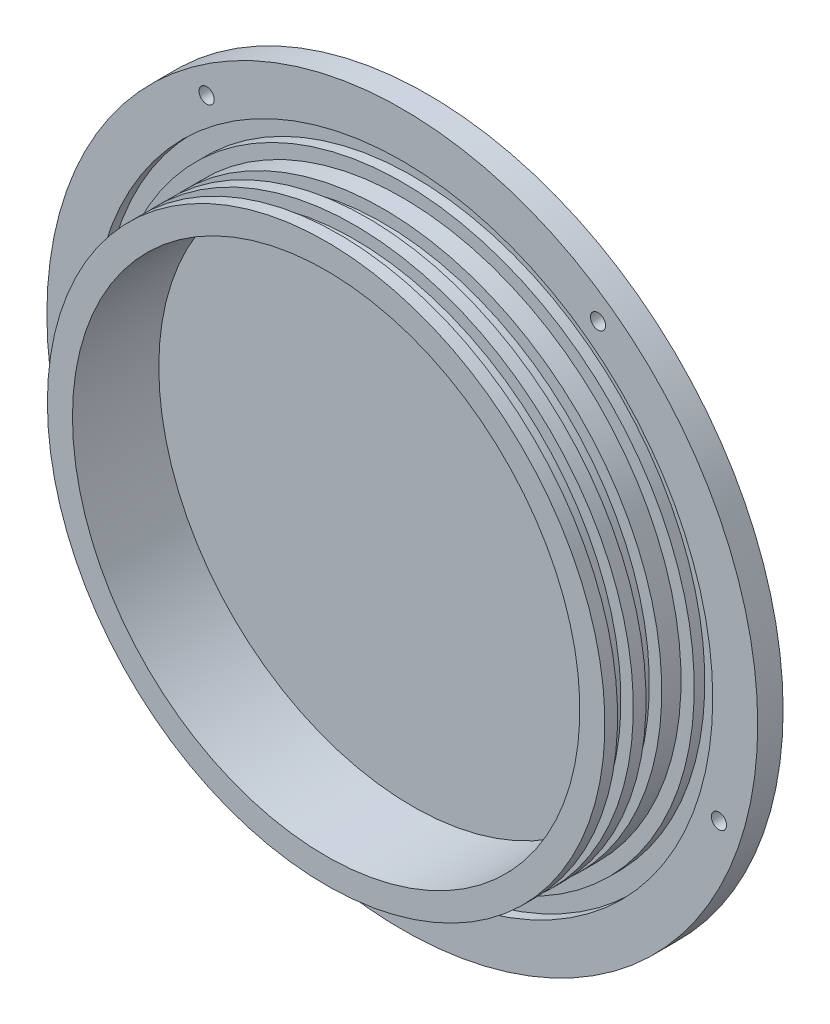
from build123d import *

# Parameters (mm, degrees)
F_6_CLEARANCE_HOLE1_D     = 3.7973
F_6_CLEARANCE_HOLE1_DEPTH = 25.4
F_6_CLEARANCE_HOLE1_TIP   = 1.140824014


with BuildPart() as part:
    # Sketch1 → Revolve1 (revolve)
    with BuildSketch(Plane(origin=(0, 0, 0), x_dir=(1, 0, 0), z_dir=(0, 1, 0))):
        Polygon((0, 0), (88.9, 0), (88.9, -6.35), (77.6478, -6.35), (77.6478, -3.7084), (73.025, -3.7084), (73.025, -6.35), (69.723, -6.35), (69.723, -11.176), (66.6242, -11.176), (66.6242, -15.113), (69.723, -15.113), (69.723, -18.288), (66.6242, -18.288), (66.6242, -22.225), (69.723, -22.225), (69.723, -25.4), (63.4492, -25.4), (63.4492, -3.811809937), (0, -3.811809937), align=None)
    revolve(axis=Axis((0, 0, 0), (0, 0, 1)))

    # #6 Clearance Hole1
    with Locations(Plane.XY.offset(6.35)):
        with Locations((0, -83.2739), (79.198185232, -25.733050288), (48.947170321, 67.370000288), (-79.198185232, -25.733050288), (-48.947170321, 67.370000288)):
            Hole(F_6_CLEARANCE_HOLE1_D / 2, depth=F_6_CLEARANCE_HOLE1_DEPTH)
            with Locations((0, 0, -(F_6_CLEARANCE_HOLE1_DEPTH + F_6_CLEARANCE_HOLE1_TIP / 2))):  # 118° drill point
                Cone(0, F_6_CLEARANCE_HOLE1_D / 2, F_6_CLEARANCE_HOLE1_TIP, mode=Mode.SUBTRACT)


solid = part.part
